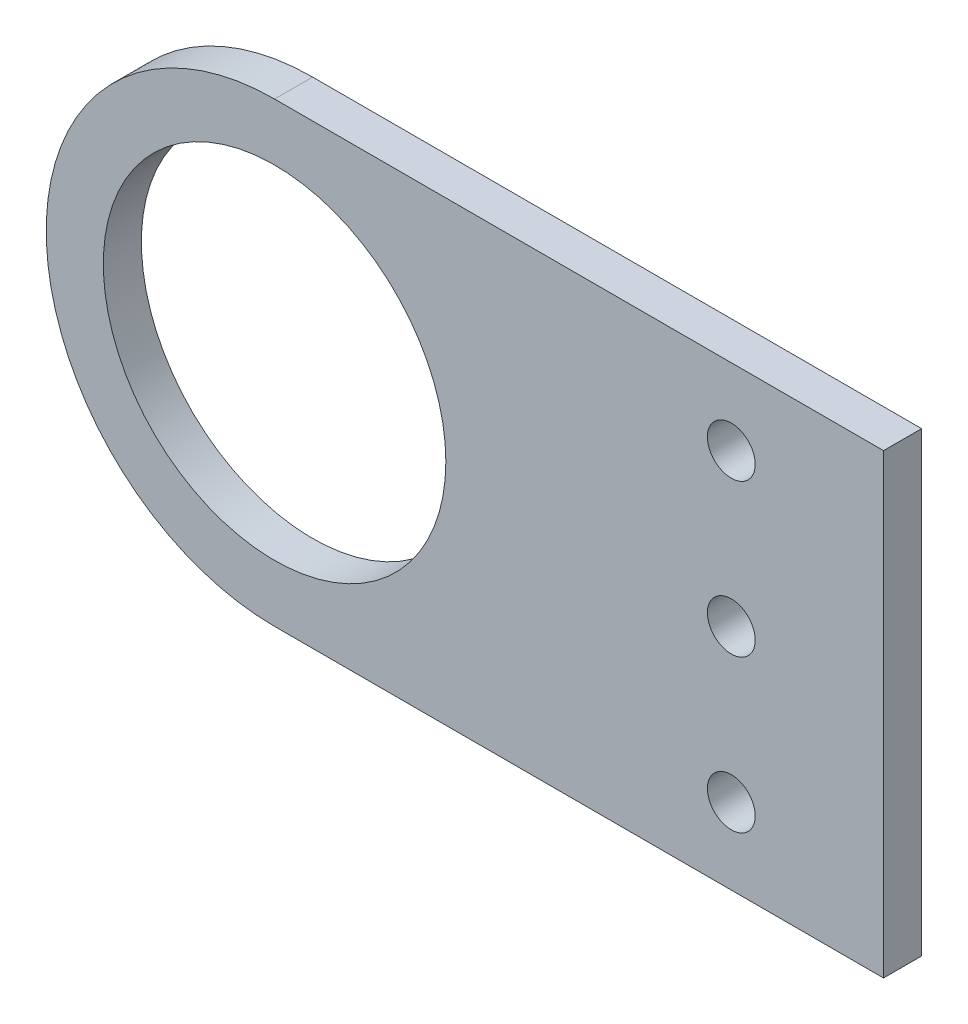
from build123d import *

# Parameters (mm, degrees)
SKETCH1_R           = 14.2875
SKETCH1_R_2         = 1.9939
BOSS_EXTRUDE1_DEPTH = 3.175


with BuildPart() as part:
    # Sketch1 → Boss-Extrude1 (new body)
    with BuildSketch(Plane.XY):
        with BuildLine():
            Line((0, 19.05), (25.4, 19.05))
            Line((25.4, 19.05), (50.8, 19.05))
            Line((50.8, 19.05), (50.8, -19.05))
            Line((50.8, -19.05), (25.4, -19.05))
            Line((25.4, -19.05), (0, -19.05))
            ThreePointArc((0, -19.05), (-19.05, 0), (0, 19.05))
        make_face()
        Circle(SKETCH1_R, mode=Mode.SUBTRACT)
        with Locations((38.1, -12.7)):
            Circle(SKETCH1_R_2, mode=Mode.SUBTRACT)
        with Locations((38.1, 0)):
            Circle(SKETCH1_R_2, mode=Mode.SUBTRACT)
        with Locations((38.1, 12.7)):
            Circle(SKETCH1_R_2, mode=Mode.SUBTRACT)
    extrude(amount=BOSS_EXTRUDE1_DEPTH)


solid = part.part
